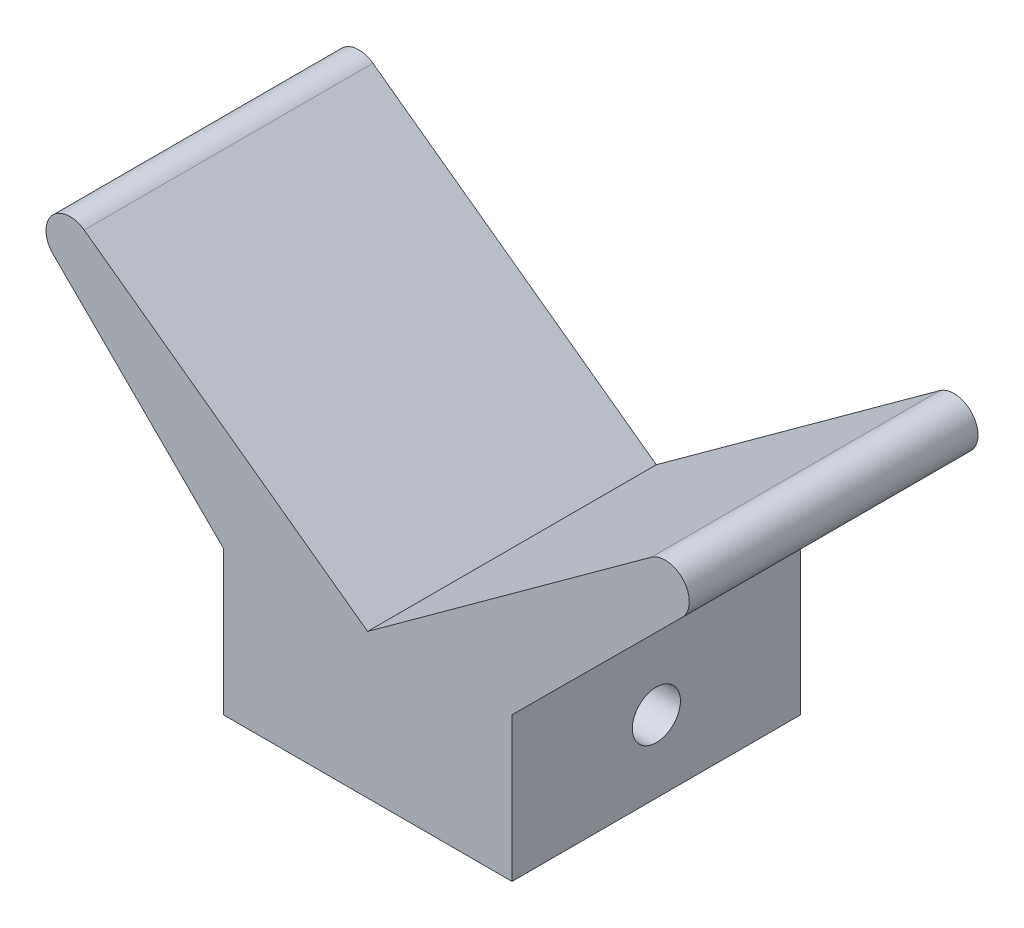
from build123d import *

# Parameters (mm, degrees)
BOSS_EXTRUDE1_DEPTH = 76.2
SKETCH2_R           = 6.35
CUT_EXTRUDE1_DEPTH  = 123.988460527


with BuildPart() as part:
    # Sketch1 → Boss-Extrude1 (new body)
    with BuildSketch(Plane.XY):
        with BuildLine():
            Line((-38.1, 0), (38.1, 0))
            Line((38.1, 0), (38.1, 38.1))
            Line((38.1, 38.1), (83.018247276, 82.81205439))
            ThreePointArc((83.018247276, 82.81205439), (83.371778793, 91.430938362), (74.806024175, 92.449757914))
            Line((74.806024175, 92.449757914), (0, 38.1))
            Line((0, 38.1), (-74.806024175, 92.449757914))
            ThreePointArc((-74.806024175, 92.449757914), (-83.371778793, 91.430938362), (-83.018247276, 82.81205439))
            Line((-83.018247276, 82.81205439), (-38.1, 38.1))
            Line((-38.1, 38.1), (-38.1, 0))
        make_face()
    extrude(amount=BOSS_EXTRUDE1_DEPTH)

    # Sketch2 → Cut-Extrude1 (cut, through all)
    with BuildSketch(Plane(origin=(38.1, 0, 0), x_dir=(0, 0, -1), z_dir=(1, 0, 0))):
        with Locations((-38.1, 19.05)):
            Circle(SKETCH2_R)
    extrude(amount=-CUT_EXTRUDE1_DEPTH, mode=Mode.SUBTRACT)


solid = part.part
